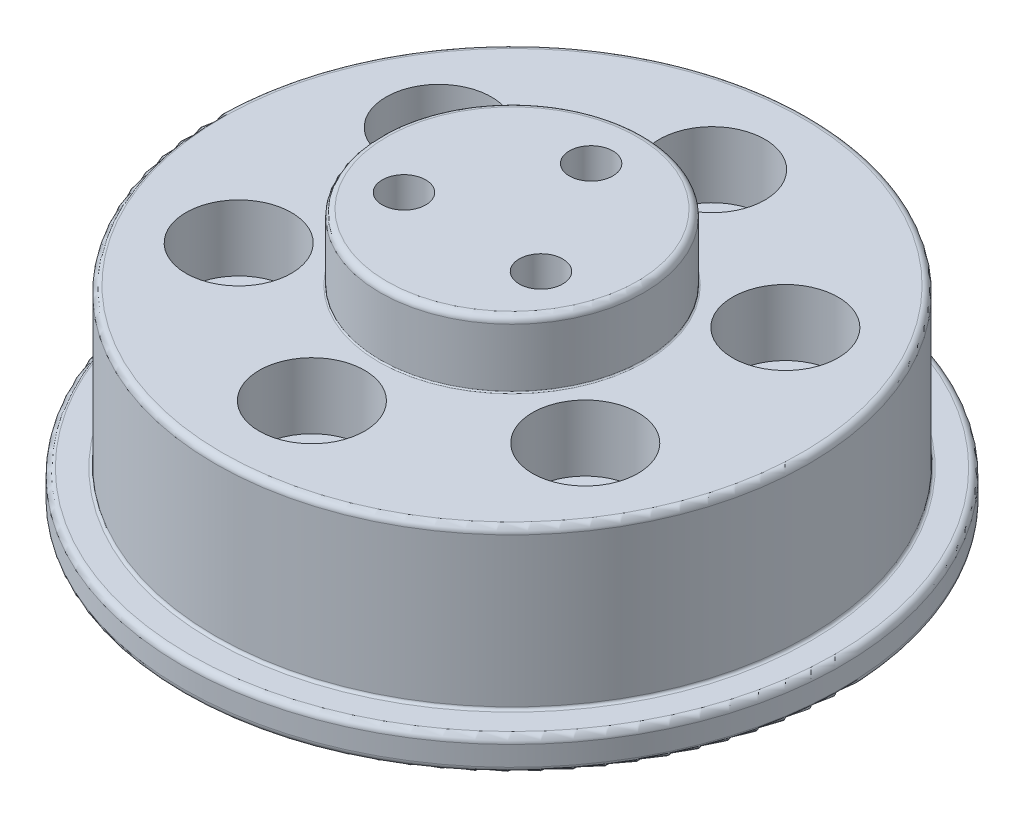
from build123d import *

# Parameters (mm, degrees)
SKETCH_1_R                   = 10.1
EXTRUDE_1_DEPTH              = 2.5
SKETCH_2_R                   = 25
EXTRUDE_2_DEPTH              = 2.5
SKETCH_3_R                   = 22.5
EXTRUDE_4_DEPTH              = 12
SKETCH_5_R                   = 10
EXTRUDE_5_DEPTH              = 5
HOLE_WIZARD_M4_1_D           = 4.5
HOLE_WIZARD_M4_1_CBORE_D     = 8
HOLE_WIZARD_M4_1_CBORE_DEPTH = 5
PATTERN_CIRCULAR_1_COUNT     = 6
PATTERN_CIRCULAR_2_COUNT     = 3
FILLET_1_R                   = 0.5
FILLET_2_R                   = 0.2
FILLET_3_R                   = 0.1
FILLET_4_R                   = 0.5


with BuildPart() as part:
    # 스케치1 → 보스-돌출1 (new body)
    with BuildSketch(Plane(origin=(0, 0, 0), x_dir=(1, 0, 0), z_dir=(0, 1, 0))):
        Circle(SKETCH_1_R)
    extrude(amount=EXTRUDE_1_DEPTH)

    # 스케치2 → 보스-돌출2 (add)
    with BuildSketch(Plane(origin=(0, 2.5, 0), x_dir=(1, 0, 0), z_dir=(0, 1, 0))):
        Circle(SKETCH_2_R)
    extrude(amount=EXTRUDE_2_DEPTH)

    # 스케치3 → 보스-돌출4 (add)
    with BuildSketch(Plane(origin=(0, 5, 0), x_dir=(1, 0, 0), z_dir=(0, 1, 0))):
        Circle(SKETCH_3_R)
    extrude(amount=EXTRUDE_4_DEPTH)

    # 스케치5 → 보스-돌출5 (add)
    with BuildSketch(Plane(origin=(0, 17, 0), x_dir=(1, 0, 0), z_dir=(0, 1, 0))):
        Circle(SKETCH_5_R)
    extrude(amount=EXTRUDE_5_DEPTH)

    # Hole Wizard M4 _ _ _ _ _ _1 (through all)
    with Locations(Plane(origin=(0, 17, 0), x_dir=(1, 0, 0), z_dir=(0, 1, 0))):
        with Locations((0, 15.18)):
            hole_wizard_m4_1 = CounterBoreHole(HOLE_WIZARD_M4_1_D / 2, HOLE_WIZARD_M4_1_CBORE_D / 2, HOLE_WIZARD_M4_1_CBORE_DEPTH)

    # 원형 패턴1: Hole Wizard M4 _ _ _ _ _ _1 ×6 about axis
    pattern_circular_1_axis = Axis((0, 0, 0), (0, 1, 0))
    for i in range(1, PATTERN_CIRCULAR_1_COUNT):
        add(hole_wizard_m4_1.rotate(pattern_circular_1_axis, i * 360 / PATTERN_CIRCULAR_1_COUNT), mode=Mode.SUBTRACT)

    # 스케치13 → Hole Wizard M4 _ _ _ _1 2 (revolve, cut)
    with BuildSketch(Plane(origin=(0, 22, -6), x_dir=(0, 0, 1), z_dir=(1, 0, 0))):
        Polygon((0, 0), (0, 5.991420021), (1.65, 5), (1.65, 0), align=None)
    hole_wizard_m4_1_2 = revolve(axis=Axis((0, 28.35, -6), (0, -1, 0)), mode=Mode.SUBTRACT)

    # 원형 패턴2: Hole Wizard M4 _ _ _ _1 2 ×3 about axis
    pattern_circular_2_axis = Axis((0, 0, 0), (0, 1, 0))
    for i in range(1, PATTERN_CIRCULAR_2_COUNT):
        add(hole_wizard_m4_1_2.rotate(pattern_circular_2_axis, i * 360 / PATTERN_CIRCULAR_2_COUNT), mode=Mode.SUBTRACT)

    # 필렛1
    fillet_1_edges = [part.edges().sort_by_distance(p)[0] for p in [
        (-22.5, 17, 0),
        (-10.1, 0, 0),
        (-10.1, 2.5, 0),
        (-25, 2.5, 0),
        (-25, 5, 0),
    ]]
    fillet(fillet_1_edges, radius=FILLET_1_R)

    # 필렛2
    fillet_2_edges = [part.edges().sort_by_distance(p)[0] for p in [
        (-22.5, 5, 0),
    ]]
    fillet(fillet_2_edges, radius=FILLET_2_R)

    # 필렛3
    fillet_3_edges = [part.edges().sort_by_distance(p)[0] for p in [
        (-10, 17, 0),
    ]]
    fillet(fillet_3_edges, radius=FILLET_3_R)

    # 필렛4
    fillet_4_edges = [part.edges().sort_by_distance(p)[0] for p in [
        (-10, 22, 0),
    ]]
    fillet(fillet_4_edges, radius=FILLET_4_R)


solid = part.part
